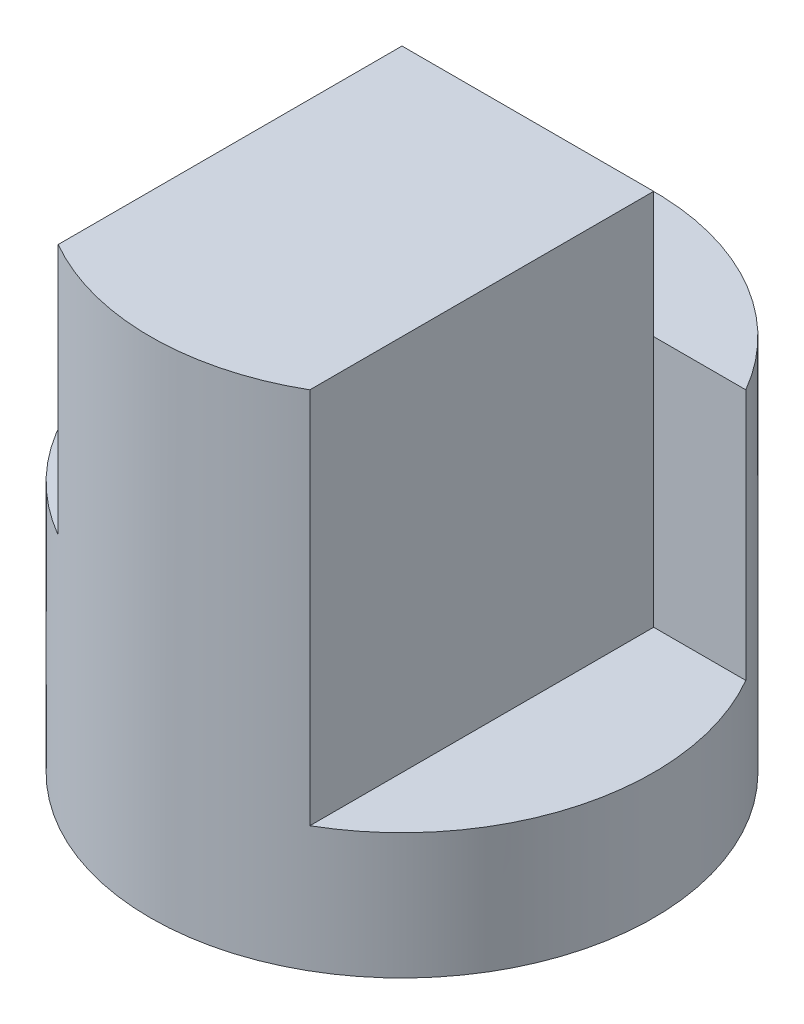
from build123d import *

# Parameters (mm, degrees)
SKETCH1_R               = 2
BOSS_EXTRUDE1_DEPTH     = 4
SKETCH2_W               = 1
SKETCH2_H               = 3
SKETCH2_H_2             = 2
CUT_EXTRUDE1_DEPTH      = 3
CUT_EXTRUDE1_DEPTH_BACK = 1
CUT_EXTRUDE2_DEPTH      = 1


with BuildPart() as part:
    # Sketch1 → Boss-Extrude1 (new body)
    with BuildSketch(Plane(origin=(0, 0, 0), x_dir=(1, 0, 0), z_dir=(0, 1, 0))):
        Circle(SKETCH1_R)
    extrude(amount=BOSS_EXTRUDE1_DEPTH)

    # Sketch2 → Cut-Extrude1 (cut, two sides)
    with BuildSketch(Plane.XY) as cut_extrude1_sk:
        with Locations((1.5, 2.5)):
            Rectangle(SKETCH2_W, SKETCH2_H)
        with Locations((-1.5, 3)):
            Rectangle(SKETCH2_W, SKETCH2_H_2)
    extrude(amount=CUT_EXTRUDE1_DEPTH, mode=Mode.SUBTRACT)
    extrude(cut_extrude1_sk.sketch, amount=-CUT_EXTRUDE1_DEPTH_BACK, mode=Mode.SUBTRACT)

    # Sketch3 → Cut-Extrude2 (cut)
    with BuildSketch(Plane(origin=(0, 4, 0), x_dir=(1, 0, 0), z_dir=(0, 1, 0))):
        with BuildLine():
            Line((-1.732050808, 1), (1.732050808, 1))
            ThreePointArc((1.732050808, 1), (0, 2), (-1.732050808, 1))
        make_face()
    extrude(amount=-CUT_EXTRUDE2_DEPTH, mode=Mode.SUBTRACT)


solid = part.part
